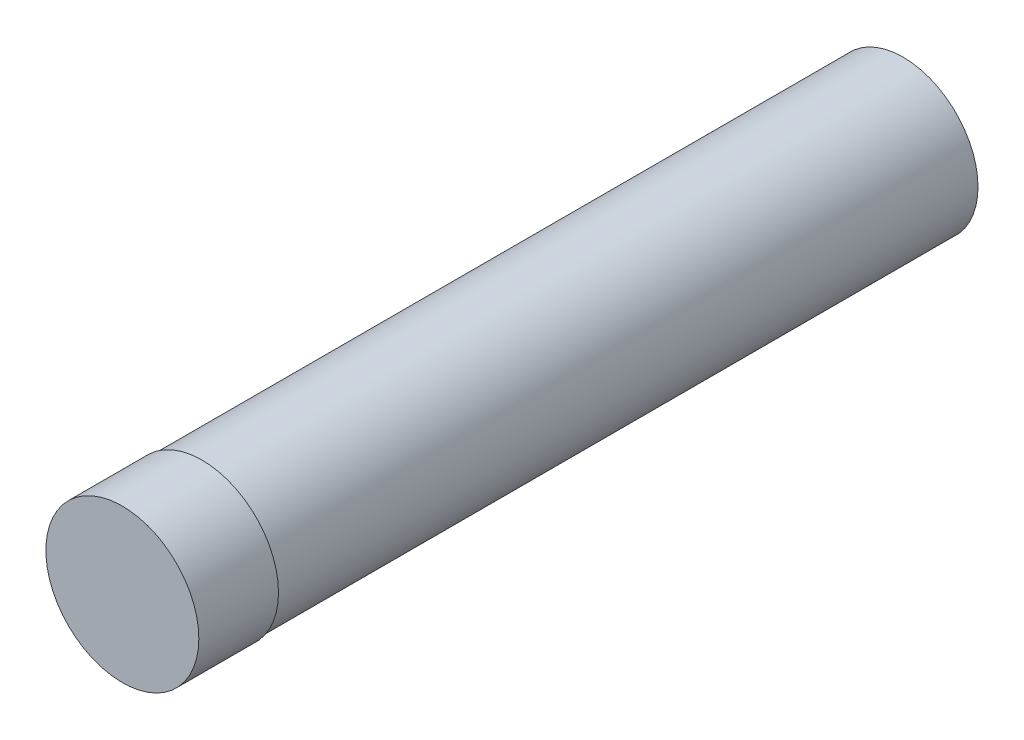
from build123d import *

# Parameters (mm, degrees)
SKETCH1_R           = 4.8
BOSS_EXTRUDE1_DEPTH = 5
SKETCH2_R           = 4.7
SKETCH2_R_2         = 3.7
EXTRUDE_THIN3_DEPTH = 44


with BuildPart() as part:
    # Sketch1 → Boss-Extrude1 (new body)
    with BuildSketch(Plane.XY):
        Circle(SKETCH1_R)
    extrude(amount=BOSS_EXTRUDE1_DEPTH)

    # Sketch2 → Extrude-Thin3 (add)
    with BuildSketch(Plane(origin=(0, 0, 0), x_dir=(-1, 0, 0), z_dir=(0, 0, -1))):
        Circle(SKETCH2_R)
        Circle(SKETCH2_R_2, mode=Mode.SUBTRACT)
    extrude(amount=EXTRUDE_THIN3_DEPTH)


solid = part.part
